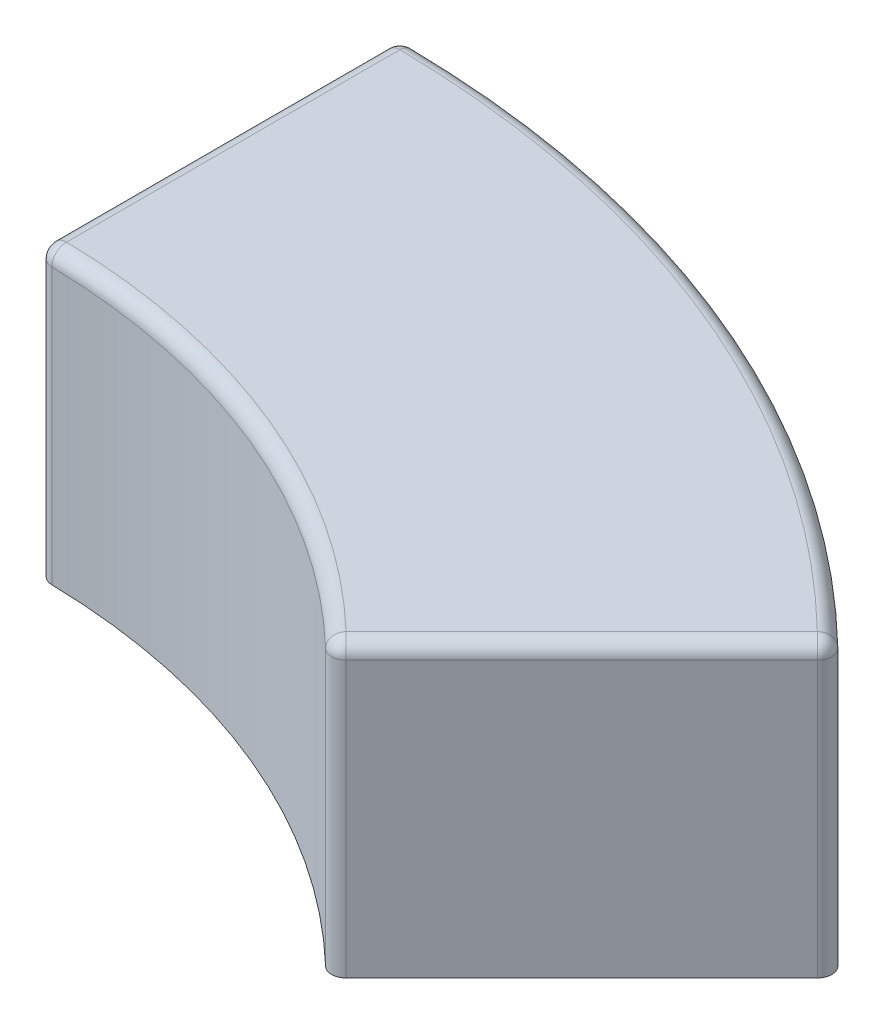
from build123d import *

# Parameters (mm, degrees)
BOSS_EXTRUDE1_DEPTH = 400
FILLET1_R           = 20
CUT_EXTRUDE1_START  = -20
CUT_EXTRUDE1_DEPTH  = 360


with BuildPart() as part:
    # Sketch1 → Boss-Extrude1 (new body)
    with BuildSketch(Plane(origin=(0, 0, 0), x_dir=(1, 0, 0), z_dir=(0, 1, 0))):
        with BuildLine():
            Line((0, 960), (0, 1460))
            ThreePointArc((0, 1460), (558.717811253, 1348.864117466), (1032.375900532, 1032.375900532))
            Line((1032.375900532, 1032.375900532), (678.822509939, 678.822509939))
            ThreePointArc((678.822509939, 678.822509939), (367.37609507, 886.924351211), (0, 960))
        make_face()
    extrude(amount=BOSS_EXTRUDE1_DEPTH)

    # Fillet1
    fillet1_edges = [part.edges().sort_by_distance(p)[0] for p in [
        (367.37609507, 400, -886.924351211),
        (855.599205236, 400, -855.599205236),
        (558.717811253, 400, -1348.864117466),
        (1032.375900532, 200, -1032.375900532),
        (678.822509939, 200, -678.822509939),
        (0, 200, -960),
        (0, 200, -1460),
        (0, 400, -1210),
    ]]
    fillet(fillet1_edges, radius=FILLET1_R)

    # Sketch4 → Cut-Extrude1 (cut)
    with BuildSketch(Plane(origin=(0, 400, 0), x_dir=(1, 0, 0), z_dir=(0, 1, 0)).offset(CUT_EXTRUDE1_START)):
        with BuildLine():
            ThreePointArc((20, 979.795897113), (375.029763718, 905.401941861), (678.678187404, 706.962458651))
            Line((678.678187404, 706.962458651), (1003.993415273, 1032.277686521))
            ThreePointArc((1003.993415273, 1032.277686521), (551.064142606, 1330.386526816), (20, 1439.861104413))
            Line((20, 1439.861104413), (20, 979.795897113))
        make_face()
    extrude(amount=-CUT_EXTRUDE1_DEPTH, mode=Mode.SUBTRACT)


solid = part.part
